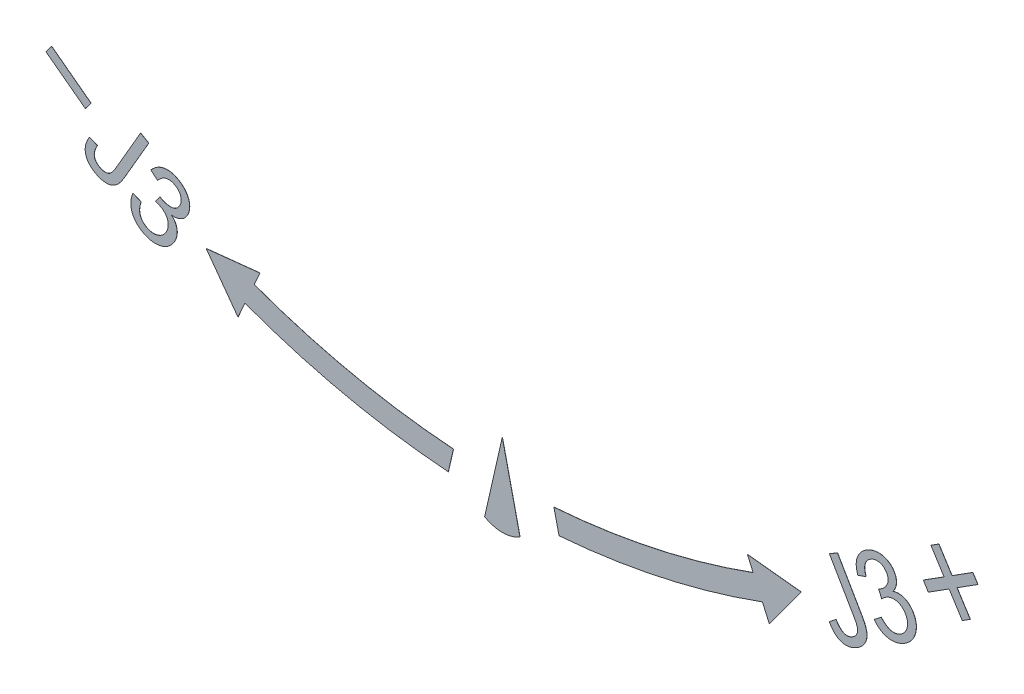
from build123d import *

# Parameters (mm, degrees)
ARROWS_DEPTH         = 0.25
ARROWS_2_DEPTH       = 0.25
ARROWS_3_DEPTH       = 0.25
ARROWS_4_DEPTH       = 0.25
ARROWS_5_DEPTH       = 0.25
EXTRUDE_J3_DEPTH     = 0.25
EXTRUDE_J3_2_DEPTH   = 0.25
EXTRUDE_J3_3_DEPTH   = 0.25
EXTRUDE_J3_3_2_DEPTH = 0.25
SCALE1_SCALE         = 0.040197


with BuildPart() as part:
    # Sketch2 → Arrows (new body)
    with BuildSketch(Plane.XY):
        Polygon((3334.452503995, 5315.005241882), (3404.956387353, 5262.127269884), (3415.176543069, 5275.523945484), (3344.562171664, 5328.484783611), align=None)
    extrude(amount=ARROWS_DEPTH)


with BuildPart() as body_2:
    # Sketch2 → Arrows 2 (new body)
    with BuildSketch(Plane.XY):
        with BuildLine():
            Line((3717.7345, 5163.4305418), (3621.4981418, 5153.2155))
            Line((3621.4981418, 5153.2155), (3678.4872582, 5075.2586582))
            Line((3678.4872582, 5075.2586582), (3690.8528418, 5103.2156))
            ThreePointArc((3690.8528418, 5103.2156), (3870.297184037, 5050.542510451), (4055.3682418, 5023.6458582))
            Line((4055.3682418, 5023.6458582), (4064.508, 5063.4307418))
            ThreePointArc((4064.508, 5063.4307418), (3883.312278545, 5089.327720839), (3707.5194582, 5140.3123))
            Line((3707.5194582, 5140.3123), (3717.7345, 5163.4305418))
        make_face()
    extrude(amount=ARROWS_2_DEPTH)


with BuildPart() as body_3:
    # Sketch2 → Arrows 3 (new body)
    with BuildSketch(Plane.XY):
        with BuildLine():
            Line((4152.1422418, 5125.7962), (4120.4218582, 4986.5491582))
            ThreePointArc((4120.4218582, 4986.5491582), (4152.1422291, 4977.889133987), (4183.8626, 4986.5491582))
            Line((4183.8626, 4986.5491582), (4152.1422418, 5125.7962))
        make_face()
    extrude(amount=ARROWS_3_DEPTH)


with BuildPart() as body_4:
    # Sketch2 → Arrows 4 (new body)
    with BuildSketch(Plane.XY):
        with BuildLine():
            Line((4244.6151582, 5063.4307418), (4253.7549418, 5023.6458582))
            ThreePointArc((4253.7549418, 5023.6458582), (4438.739441527, 5050.939039788), (4618.2703418, 5103.2156))
            Line((4618.2703418, 5103.2156), (4630.6359, 5075.2586582))
            Line((4630.6359, 5075.2586582), (4687.6250418, 5153.2155))
            Line((4687.6250418, 5153.2155), (4591.3886582, 5163.4305418))
            Line((4591.3886582, 5163.4305418), (4601.6037, 5140.3123))
            ThreePointArc((4601.6037, 5140.3123), (4425.773813147, 5089.49983388), (4244.6151582, 5063.4307418))
        make_face()
    extrude(amount=ARROWS_4_DEPTH)


with BuildPart() as body_5:
    # Sketch2 → Arrows 5 (new body)
    with BuildSketch(Plane.XY):
        Polygon((4943.789009697, 5304.797458242), (4906.53658973, 5281.186780004), (4915.556982848, 5266.954597881), (4952.809402815, 5290.565276119), (4976.420081053, 5253.312856151), (4990.652263176, 5262.33324927), (4967.041584938, 5299.585669237), (5004.294004906, 5323.196347475), (4995.273611787, 5337.428529598), (4958.02119182, 5313.81785136), (4934.410513582, 5351.070271327), (4920.178331459, 5342.049878209), align=None)
    extrude(amount=ARROWS_5_DEPTH)


with BuildPart() as body_6:
    # Sketch3 → Extrude J3 (new body)
    with BuildSketch(Plane.XY):
        with BuildLine():
            Line((3412.234669017, 5221.497851265), (3426.447409402, 5215.683548381))
            add(Edge.make_bspline(
                [(3426.447409402, 5215.683548381), (3425.907825179, 5214.648030824), (3424.868903002, 5212.654232434), (3423.600083312, 5209.676743101), (3422.513780011, 5206.904303824), (3421.701571316, 5204.307723437), (3421.188583028, 5201.883443078), (3420.869034172, 5199.645772534), (3420.876839735, 5197.579115798), (3421.097172013, 5195.673890927), (3421.587957166, 5193.92210397), (3422.220750805, 5192.255079287), (3423.092606822, 5190.694695951), (3424.134881311, 5189.224473751), (3425.321495291, 5187.806559807), (3426.741464141, 5186.515097147), (3428.332870346, 5185.303236172), (3429.498467296, 5184.594792296), (3430.09103921, 5184.234630111)],
                knots=[0, 0, 0, 0, 0.003501669, 0.006742158, 0.00970322, 0.012433367, 0.014891557, 0.017132018, 0.019199326, 0.021074382, 0.022867146, 0.024642693, 0.026412212, 0.028211668, 0.030044765, 0.031946519, 0.033957003, 0.036036067, 0.036036067, 0.036036067, 0.036036067], degree=3))
            add(Edge.make_bspline(
                [(3430.09103921, 5184.234630111), (3430.992556106, 5183.752706915), (3432.748125218, 5182.814233679), (3435.510512155, 5181.863242501), (3438.255851414, 5181.290401314), (3440.978146199, 5181.196890194), (3443.61607558, 5181.490834727), (3446.102895484, 5182.228631124), (3448.418849178, 5183.349409124), (3450.177205592, 5184.651000329), (3451.535445233, 5185.909398717), (3452.602136673, 5187.061763331), (3453.694503891, 5188.405812944), (3454.873481663, 5189.910813388), (3456.083141746, 5191.621958488), (3457.335770198, 5193.521282006), (3458.640526424, 5195.604359996), (3459.493972755, 5197.066707502), (3459.937794017, 5197.827178188)],
                knots=[0, 0, 0, 0, 0.003062499, 0.005963759, 0.008730835, 0.011446144, 0.01410014, 0.016659477, 0.019190478, 0.021780034, 0.023188091, 0.024742228, 0.026485897, 0.028382905, 0.030476692, 0.032770175, 0.035208043, 0.037849428, 0.037849428, 0.037849428, 0.037849428], degree=3))
            Line((3459.937794017, 5197.827178188), (3503.945606517, 5273.697370496))
            Line((3503.945606517, 5273.697370496), (3518.520125748, 5265.247250304))
            Line((3518.520125748, 5265.247250304), (3475.003298825, 5190.203981073))
            add(Edge.make_bspline(
                [(3475.003298825, 5190.203981073), (3474.348256837, 5189.08782766), (3473.075207943, 5186.91862646), (3471.08457427, 5183.84007894), (3469.091952121, 5181.028815442), (3467.137745433, 5178.444236224), (3465.142948049, 5176.165304305), (3463.199747011, 5174.090020997), (3461.252221663, 5172.288074338), (3459.284941646, 5170.74086057), (3457.306325301, 5169.411072566), (3455.279417136, 5168.263457621), (3453.197180393, 5167.307887487), (3451.047184742, 5166.556798333), (3448.855642451, 5165.960543931), (3446.592681221, 5165.533953414), (3444.273143095, 5165.350468663), (3441.108553457, 5165.260050335), (3437.08514313, 5165.697738066), (3432.236048826, 5166.808400578), (3427.364671143, 5168.63552157), (3424.249580199, 5170.31940219), (3422.648731517, 5171.184750304)],
                knots=[0, 0, 0, 0, 0.003882227, 0.007544959, 0.010993592, 0.014218795, 0.017259961, 0.020074889, 0.022744939, 0.025210859, 0.027576013, 0.02989022, 0.032191406, 0.034439009, 0.036714515, 0.039000416, 0.041335307, 0.043687437, 0.048490662, 0.053423923, 0.058583722, 0.064038634, 0.064038634, 0.064038634, 0.064038634], degree=3))
            add(Edge.make_bspline(
                [(3422.648731517, 5171.184750304), (3421.489124696, 5171.887454467), (3419.229652914, 5173.256660133), (3416.163633248, 5175.602138508), (3413.414031861, 5178.029363563), (3411.044246775, 5180.625747732), (3409.054280336, 5183.371511327), (3407.395251421, 5186.238718229), (3406.129604961, 5189.253385127), (3405.211262882, 5192.398653373), (3404.700740269, 5195.671963207), (3404.566125217, 5199.063763941), (3404.869600416, 5202.563976115), (3405.547811085, 5206.163763161), (3406.622379973, 5209.866641095), (3408.120832083, 5213.665383727), (3409.967279917, 5217.595999242), (3411.465080229, 5220.173499141), (3412.234669017, 5221.497851265)],
                knots=[0, 0, 0, 0, 0.004064984, 0.007920544, 0.011562341, 0.015056278, 0.018441889, 0.02171763, 0.024971691, 0.028226675, 0.031523447, 0.034885306, 0.038385449, 0.042039693, 0.045859058, 0.049933314, 0.054279579, 0.058872801, 0.058872801, 0.058872801, 0.058872801], degree=3))
        make_face()
    extrude(amount=EXTRUDE_J3_DEPTH)


with BuildPart() as body_7:
    # Sketch3 → Extrude J3 2 (new body)
    with BuildSketch(Plane.XY):
        with BuildLine():
            Line((3490.273570282, 5173.347957036), (3504.822248166, 5167.301082036))
            add(Edge.make_bspline(
                [(3504.822248166, 5167.301082036), (3504.482317338, 5166.26264159), (3503.821905369, 5164.245176733), (3503.067289604, 5161.241049969), (3502.56627198, 5158.379213499), (3502.200907297, 5155.665401962), (3502.09484397, 5153.08748777), (3502.225543455, 5150.64016088), (3502.553999094, 5148.336935763), (3503.097274235, 5146.170332174), (3503.857297971, 5144.140752142), (3504.793482222, 5142.225783274), (3505.876144888, 5140.41422255), (3507.119840783, 5138.716358982), (3508.567402222, 5137.159119479), (3510.158982769, 5135.690456569), (3511.920926843, 5134.335626535), (3513.19584077, 5133.558066775), (3513.840877974, 5133.164663767)],
                knots=[0, 0, 0, 0, 0.003277371, 0.006367223, 0.009281801, 0.011990216, 0.014576417, 0.017008938, 0.019333223, 0.02154564, 0.023696069, 0.025822609, 0.027932124, 0.030020163, 0.032123496, 0.034299853, 0.036511969, 0.038777328, 0.038777328, 0.038777328, 0.038777328], degree=3))
            add(Edge.make_bspline(
                [(3513.840877974, 5133.164663767), (3514.635372911, 5132.737971487), (3516.2024445, 5131.896358385), (3518.635136102, 5130.879457811), (3521.10677752, 5130.152559361), (3523.601576435, 5129.693910523), (3526.118631989, 5129.442169546), (3528.665890578, 5129.507818164), (3531.236229392, 5129.818178247), (3533.803207745, 5130.390942188), (3536.318474686, 5131.175756614), (3538.713113001, 5132.210058158), (3540.935106491, 5133.498321612), (3543.051765158, 5134.937002468), (3544.998303474, 5136.631998094), (3546.779941312, 5138.554023561), (3548.420851569, 5140.684867449), (3549.377212084, 5142.226158791), (3549.863714512, 5143.010216651)],
                knots=[0, 0, 0, 0, 0.002704467, 0.005334324, 0.007893661, 0.010417661, 0.012935038, 0.015468017, 0.018045035, 0.020690967, 0.023347101, 0.025939491, 0.028497262, 0.031041946, 0.033606627, 0.036221204, 0.038893379, 0.041660214, 0.041660214, 0.041660214, 0.041660214], degree=3))
            add(Edge.make_bspline(
                [(3549.863714512, 5143.010216651), (3550.282541871, 5143.77853387), (3551.108160455, 5145.293088645), (3552.082868241, 5147.63959978), (3552.821547596, 5150.000378958), (3553.313284327, 5152.362919777), (3553.551059795, 5154.744945861), (3553.525849748, 5157.128425514), (3553.23030935, 5159.515645438), (3552.719963591, 5161.888822988), (3551.965748717, 5164.204144331), (3551.026286173, 5166.435131041), (3549.8170905, 5168.511501726), (3548.418384771, 5170.462084289), (3546.796550731, 5172.277164337), (3544.993564327, 5173.986852045), (3542.958812929, 5175.555392431), (3541.474629312, 5176.454444945), (3540.715877974, 5176.914062805)],
                knots=[0, 0, 0, 0, 0.002623756, 0.005172111, 0.007607786, 0.01003536, 0.012398396, 0.01477594, 0.017170277, 0.019603209, 0.022046686, 0.024465993, 0.026850689, 0.029238882, 0.03165529, 0.034141437, 0.036684415, 0.039344191, 0.039344191, 0.039344191, 0.039344191], degree=3))
            add(Edge.make_bspline(
                [(3540.715877974, 5176.914062805), (3540.023676549, 5177.287234596), (3538.556464952, 5178.078221093), (3536.109853562, 5179.089891661), (3533.334758959, 5180.080542606), (3531.347858924, 5180.647058912), (3530.301815474, 5180.945312805)],
                knots=[0, 0, 0, 0, 0.002357802, 0.004997669, 0.007931886, 0.011194144, 0.011194144, 0.011194144, 0.011194144], degree=3))
            Line((3530.301815474, 5180.945312805), (3538.700252974, 5191.927884921))
            add(Edge.make_bspline(
                [(3538.700252974, 5191.927884921), (3539.074801893, 5191.645709633), (3539.743450205, 5191.141967612), (3540.454716228, 5190.700699144), (3540.767560666, 5190.506610882)],
                knots=[0, 0, 0, 0, 0.001405921, 0.002509864, 0.002509864, 0.002509864, 0.002509864], degree=3))
            add(Edge.make_bspline(
                [(3540.767560666, 5190.506610882), (3542.203847048, 5189.748285865), (3545.036879045, 5188.252512413), (3549.576027309, 5186.784789708), (3554.214997554, 5186.002678219), (3558.124204101, 5185.897634508), (3561.217261048, 5186.210454008), (3563.434621614, 5186.758986318), (3565.523893047, 5187.590374058), (3567.470796588, 5188.717861786), (3569.301487559, 5190.098580985), (3570.986342398, 5191.773145821), (3572.543403086, 5193.718349363), (3573.437397822, 5195.165052098), (3573.896166435, 5195.907452228)],
                knots=[0, 0, 0, 0, 0.004865453, 0.00959696, 0.014236112, 0.018940372, 0.021280406, 0.023542963, 0.025769521, 0.028003565, 0.030272459, 0.032629694, 0.035111674, 0.037727911, 0.037727911, 0.037727911, 0.037727911], degree=3))
            add(Edge.make_bspline(
                [(3573.896166435, 5195.907452228), (3574.23633915, 5196.521299384), (3574.906286609, 5197.730230388), (3575.674200429, 5199.622971553), (3576.25033733, 5201.516374261), (3576.621086725, 5203.421885784), (3576.763308631, 5205.336314292), (3576.757360236, 5207.26943013), (3576.475623301, 5209.20494101), (3576.049217253, 5211.148112753), (3575.403447264, 5213.03099049), (3574.599115029, 5214.84891038), (3573.586424342, 5216.552374434), (3572.390404912, 5218.154100342), (3571.031667328, 5219.676045213), (3569.488356451, 5221.083194296), (3567.757761477, 5222.397707384), (3566.504180073, 5223.163746146), (3565.859507782, 5223.557692613)],
                knots=[0, 0, 0, 0, 0.002103809, 0.004143312, 0.006113535, 0.008034331, 0.009952866, 0.0118653, 0.013820553, 0.015807818, 0.017826257, 0.019780997, 0.021762036, 0.023757015, 0.025769988, 0.027873321, 0.030013009, 0.032278368, 0.032278368, 0.032278368, 0.032278368], degree=3))
            add(Edge.make_bspline(
                [(3565.859507782, 5223.557692613), (3564.555001169, 5224.239453722), (3562.030657552, 5225.55872592), (3557.945227778, 5226.62647225), (3553.846152738, 5226.904444798), (3550.441256672, 5226.416263547), (3547.772392164, 5225.625238539), (3545.766751999, 5224.824383643), (3543.805441655, 5223.774246489), (3541.844573853, 5222.534512886), (3539.956065623, 5221.027483935), (3538.074604113, 5219.327847007), (3536.209197096, 5217.419362833), (3535.038332536, 5216.011959874), (3534.436430858, 5215.288461844)],
                knots=[0, 0, 0, 0, 0.004404036, 0.008522225, 0.012561749, 0.016658479, 0.018759906, 0.020904894, 0.023124243, 0.025425284, 0.02785492, 0.03036153, 0.033029579, 0.035852088, 0.035852088, 0.035852088, 0.035852088], degree=3))
            Line((3534.436430858, 5215.288461844), (3522.316839512, 5225.521634921))
            add(Edge.make_bspline(
                [(3522.316839512, 5225.521634921), (3523.180015788, 5226.501015927), (3524.865491528, 5228.413398105), (3527.609278889, 5230.984756159), (3530.428038401, 5233.260445918), (3533.314530681, 5235.267595734), (3536.305363688, 5236.928105698), (3539.378027951, 5238.280754917), (3542.53244894, 5239.346695227), (3545.769936404, 5240.095516168), (3549.049307417, 5240.534114618), (3552.345684761, 5240.665114806), (3555.642146828, 5240.482330727), (3558.929254952, 5239.988841604), (3562.218860112, 5239.182141048), (3565.485439142, 5238.03121032), (3568.774561732, 5236.609175707), (3570.898736196, 5235.445066073), (3571.98390682, 5234.850360882)],
                knots=[0, 0, 0, 0, 0.003914601, 0.007643822, 0.011263917, 0.014776154, 0.018177115, 0.021509346, 0.024835259, 0.028151218, 0.031462341, 0.034746734, 0.038033567, 0.041351942, 0.044705049, 0.048178284, 0.051730976, 0.055441527, 0.055441527, 0.055441527, 0.055441527], degree=3))
            add(Edge.make_bspline(
                [(3571.98390682, 5234.850360882), (3573.436945837, 5233.944523064), (3576.298040402, 5232.160890532), (3580.146492742, 5228.941415632), (3583.538605799, 5225.356315853), (3586.404124654, 5221.417117893), (3588.771043694, 5217.278159375), (3590.508008929, 5212.97940209), (3591.55233718, 5208.56110689), (3591.927275217, 5204.095805388), (3591.718535719, 5199.692842113), (3590.978511273, 5195.427791912), (3589.631743996, 5191.351186378), (3588.308403541, 5188.827969932), (3587.643762589, 5187.560697421)],
                knots=[0, 0, 0, 0, 0.005131769, 0.010104667, 0.015003903, 0.019903752, 0.024682794, 0.029275071, 0.033762918, 0.038250243, 0.042673947, 0.046952231, 0.051201542, 0.055489181, 0.055489181, 0.055489181, 0.055489181], degree=3))
            add(Edge.make_bspline(
                [(3587.643762589, 5187.560697421), (3586.919006217, 5186.416450249), (3585.494876844, 5184.168031234), (3582.793264008, 5181.233803902), (3579.722695105, 5178.734110044), (3576.278382835, 5176.687062962), (3572.491007389, 5175.149470346), (3568.408976777, 5174.165593505), (3564.037466386, 5173.779494983), (3561.061328327, 5173.955180974), (3559.528377974, 5174.045673382)],
                knots=[0, 0, 0, 0, 0.00405668, 0.007971281, 0.011902225, 0.015899707, 0.019945012, 0.02411925, 0.028452128, 0.0330545, 0.0330545, 0.0330545, 0.0330545], degree=3))
            add(Edge.make_bspline(
                [(3559.528377974, 5174.045673382), (3560.201862466, 5173.383569909), (3561.529174841, 5172.078687401), (3563.314740287, 5169.981943955), (3564.867097105, 5167.809769633), (3566.203139807, 5165.56419426), (3567.310644263, 5163.246437485), (3568.196531358, 5160.859789277), (3568.844580134, 5158.400815505), (3569.284005437, 5155.885491309), (3569.490401335, 5153.316365697), (3569.464423923, 5150.730351026), (3569.201913666, 5148.127780281), (3568.706264562, 5145.509044959), (3567.979524483, 5142.873736333), (3567.023729351, 5140.224353762), (3565.793044586, 5137.585964684), (3564.84430792, 5135.855583023), (3564.360709705, 5134.973557998)],
                knots=[0, 0, 0, 0, 0.002832311, 0.005581956, 0.008249504, 0.010833251, 0.013410788, 0.015945348, 0.018458876, 0.021029148, 0.023595781, 0.026180044, 0.028777068, 0.031432824, 0.034166149, 0.036970025, 0.039872205, 0.042889562, 0.042889562, 0.042889562, 0.042889562], degree=3))
            add(Edge.make_bspline(
                [(3564.360709705, 5134.973557998), (3563.640701113, 5133.813996189), (3562.221344975, 5131.528146837), (3559.761963001, 5128.385093176), (3557.021160357, 5125.608559672), (3554.059662955, 5123.131272565), (3550.841593727, 5120.975055099), (3547.356840371, 5119.159737864), (3543.621379737, 5117.689185482), (3539.682922369, 5116.56344369), (3535.636313374, 5115.786495968), (3531.541624116, 5115.420192555), (3527.462835995, 5115.469282812), (3523.387235366, 5115.947735012), (3519.320716661, 5116.816526063), (3515.279236542, 5118.170132657), (3511.22000728, 5119.861877616), (3508.608707744, 5121.29584639), (3507.277176051, 5122.027043575)],
                knots=[0, 0, 0, 0, 0.004092816, 0.008068186, 0.011942147, 0.015776867, 0.019632774, 0.02353952, 0.027541593, 0.031655565, 0.035811445, 0.039884634, 0.043967894, 0.048025891, 0.052177028, 0.056418237, 0.060795429, 0.065349668, 0.065349668, 0.065349668, 0.065349668], degree=3))
            add(Edge.make_bspline(
                [(3507.277176051, 5122.027043575), (3506.109180057, 5122.738863513), (3503.816502157, 5124.136106186), (3500.668432775, 5126.544630392), (3497.766271805, 5129.059060292), (3495.231828838, 5131.821935643), (3492.990496413, 5134.749191531), (3491.08541657, 5137.869553228), (3489.425260594, 5141.137617192), (3488.152478154, 5144.594700284), (3487.204958702, 5148.143298796), (3486.568022591, 5151.722192505), (3486.319031168, 5155.31511737), (3486.385163646, 5158.915906165), (3486.842485068, 5162.530158793), (3487.614133635, 5166.156654233), (3488.754299408, 5169.788784292), (3489.762176389, 5172.14992235), (3490.273570282, 5173.347957036)],
                knots=[0, 0, 0, 0, 0.00410064, 0.008049211, 0.011875563, 0.015606037, 0.019275599, 0.022918771, 0.0265591, 0.030255045, 0.033947103, 0.037566737, 0.041142193, 0.044734977, 0.048353688, 0.052053606, 0.055845862, 0.05975201, 0.05975201, 0.05975201, 0.05975201], degree=3))
        make_face()
    extrude(amount=EXTRUDE_J3_2_DEPTH)


with BuildPart() as body_8:
    # Sketch4 → Extrude J3 3 (new body)
    with BuildSketch(Plane.XY):
        with BuildLine():
            Line((4737.998555778, 5132.457239626), (4750.092305778, 5141.889330972))
            add(Edge.make_bspline(
                [(4750.092305778, 5141.889330972), (4750.729282759, 5140.909841493), (4751.954313628, 5139.026092339), (4753.860888128, 5136.414460486), (4755.749828141, 5134.125971487), (4757.618947637, 5132.153577996), (4759.436761002, 5130.459043856), (4761.246714568, 5129.105010458), (4763.033318574, 5128.06851429), (4764.801329474, 5127.342171163), (4766.564427786, 5126.860312145), (4768.338181716, 5126.642820486), (4770.12214357, 5126.5797564), (4771.925329008, 5126.742626316), (4773.736750694, 5127.104457275), (4775.560039593, 5127.686383371), (4777.404687656, 5128.461519156), (4778.600991675, 5129.120923885), (4779.215502893, 5129.459643472)],
                knots=[0, 0, 0, 0, 0.003504719, 0.006740258, 0.009694886, 0.012400217, 0.014887706, 0.017141095, 0.0191668, 0.021067149, 0.022859913, 0.024632449, 0.02641625, 0.028206032, 0.030050749, 0.031946877, 0.033938673, 0.036042483, 0.036042483, 0.036042483, 0.036042483], degree=3))
            add(Edge.make_bspline(
                [(4779.215502893, 5129.459643472), (4780.086782786, 5129.993857825), (4781.78163353, 5131.03303433), (4783.956218836, 5132.982122656), (4785.800139238, 5135.088010275), (4787.253069861, 5137.388511927), (4788.290347953, 5139.833755204), (4788.93129776, 5142.344171889), (4789.082063594, 5144.918919354), (4788.775685211, 5147.607950632), (4787.935448832, 5150.572466103), (4786.549272478, 5153.965045674), (4784.618517197, 5157.888962234), (4783.071963768, 5160.640849889), (4782.238940393, 5162.123105011)],
                knots=[0, 0, 0, 0, 0.003060427, 0.005953273, 0.008719746, 0.011437022, 0.01407689, 0.016659086, 0.019170487, 0.021770209, 0.024741514, 0.028383677, 0.032752317, 0.037852564, 0.037852564, 0.037852564, 0.037852564], degree=3))
            Line((4782.238940393, 5162.123105011), (4738.231127893, 5237.993297319))
            Line((4738.231127893, 5237.993297319), (4752.805647124, 5246.443417511))
            Line((4752.805647124, 5246.443417511), (4796.322474047, 5171.40014828))
            add(Edge.make_bspline(
                [(4796.322474047, 5171.40014828), (4796.958950664, 5170.275941893), (4798.197150204, 5168.088914445), (4799.876000005, 5164.829688533), (4801.35016138, 5161.713636075), (4802.614394824, 5158.729221564), (4803.600899112, 5155.860540117), (4804.453846398, 5153.147752667), (4805.056909172, 5150.556792339), (4805.411712358, 5148.083111743), (4805.61169647, 5145.700381295), (4805.577713551, 5143.374592312), (4805.369898222, 5141.08549883), (4804.991533856, 5138.833680093), (4804.387476092, 5136.632474787), (4803.605237624, 5134.474296899), (4802.650933726, 5132.355083657), (4801.121372739, 5129.58408753), (4798.790252655, 5126.280596514), (4795.372100166, 5122.662887018), (4791.38515867, 5119.324061737), (4788.363474265, 5117.466407722), (4786.812858663, 5116.513129049)],
                knots=[0, 0, 0, 0, 0.00387534, 0.007539075, 0.010995445, 0.014215675, 0.017255962, 0.020092513, 0.022744117, 0.02522556, 0.027584069, 0.029909934, 0.03219335, 0.034474718, 0.036750224, 0.03903086, 0.041355576, 0.043714935, 0.048518437, 0.053436515, 0.05861124, 0.064065785, 0.064065785, 0.064065785, 0.064065785], degree=3))
            add(Edge.make_bspline(
                [(4786.812858663, 5116.513129049), (4785.626549797, 5115.853506819), (4783.31650773, 5114.569056247), (4779.758645237, 5113.061479475), (4776.289300094, 5111.857083671), (4772.851803984, 5111.120754957), (4769.485076896, 5110.702061952), (4766.171315443, 5110.746266075), (4762.925654013, 5111.121029669), (4759.750536002, 5111.907874801), (4756.648657129, 5113.077423228), (4753.650665449, 5114.6637987), (4750.754123831, 5116.648510311), (4747.991392292, 5119.057128186), (4745.294489765, 5121.818100333), (4742.746575822, 5125.009384871), (4740.239061449, 5128.542696261), (4738.760703403, 5131.125638477), (4737.998555778, 5132.457239626)],
                knots=[0, 0, 0, 0, 0.004069253, 0.00792386, 0.011576642, 0.01506905, 0.018450714, 0.021732667, 0.024986009, 0.028232571, 0.031520216, 0.03490701, 0.038383319, 0.04202988, 0.045885787, 0.04994584, 0.054268766, 0.058868961, 0.058868961, 0.058868961, 0.058868961], degree=3))
        make_face()
    extrude(amount=EXTRUDE_J3_3_DEPTH)


with BuildPart() as body_9:
    # Sketch4 → Extrude J3 3 2 (new body)
    with BuildSketch(Plane.XY):
        with BuildLine():
            Line((4818.608068327, 5176.199898071), (4831.089438519, 5185.812878841))
            add(Edge.make_bspline(
                [(4831.089438519, 5185.812878841), (4831.820815394, 5185.002845259), (4833.24229141, 5183.428495089), (4835.470567999, 5181.280696029), (4837.689773635, 5179.39125525), (4839.889845723, 5177.758121292), (4842.059694947, 5176.361968189), (4844.246983086, 5175.286670358), (4846.398226517, 5174.408582347), (4848.551836235, 5173.818623401), (4850.690540618, 5173.45396351), (4852.810917322, 5173.296946707), (4854.922591363, 5173.349795633), (4857.018185415, 5173.605768726), (4859.089685436, 5174.083062457), (4861.156077898, 5174.724810687), (4863.190113645, 5175.609851593), (4864.507490772, 5176.327635621), (4865.174174096, 5176.690883648)],
                knots=[0, 0, 0, 0, 0.003273294, 0.006361848, 0.009276885, 0.012010943, 0.014577576, 0.017004462, 0.019312602, 0.021538261, 0.023687913, 0.025812568, 0.027906355, 0.030015395, 0.032134386, 0.034275634, 0.03649814, 0.03877526, 0.03877526, 0.03877526, 0.03877526], degree=3))
            add(Edge.make_bspline(
                [(4865.174174096, 5176.690883648), (4865.943589528, 5177.15669368), (4867.464134568, 5178.077243364), (4869.517422629, 5179.727333169), (4871.403311192, 5181.474993899), (4873.033958451, 5183.417900881), (4874.494183038, 5185.478814822), (4875.716560539, 5187.716492188), (4876.6856458, 5190.118308913), (4877.500215545, 5192.624995413), (4878.014940738, 5195.211064064), (4878.354988499, 5197.793006005), (4878.36777989, 5200.367305885), (4878.137783572, 5202.920351006), (4877.651782849, 5205.454816218), (4876.845059169, 5207.940624406), (4875.861387432, 5210.443119005), (4874.978168874, 5212.033605029), (4874.528741404, 5212.842926917)],
                knots=[0, 0, 0, 0, 0.002695439, 0.005326819, 0.007886026, 0.010397427, 0.012920898, 0.015453482, 0.018025702, 0.020681835, 0.02334763, 0.025924649, 0.028483073, 0.031051916, 0.03360616, 0.036205239, 0.038882907, 0.041657093, 0.041657093, 0.041657093, 0.041657093], degree=3))
            add(Edge.make_bspline(
                [(4874.528741404, 5212.842926917), (4874.067872952, 5213.592245925), (4873.162731754, 5215.063901233), (4871.60995076, 5217.085932704), (4869.916348521, 5218.87016937), (4868.122929741, 5220.484279574), (4866.15447973, 5221.835401356), (4864.074531884, 5223.012250124), (4861.870201275, 5223.978431062), (4859.541370317, 5224.685004662), (4857.166984413, 5225.208473919), (4854.766910446, 5225.472417285), (4852.37707314, 5225.463651368), (4849.986354438, 5225.236441235), (4847.602683877, 5224.744582867), (4845.2407464, 5223.974713313), (4842.869468906, 5223.002015029), (4841.349363958, 5222.16150604), (4840.573212557, 5221.732349994)],
                knots=[0, 0, 0, 0, 0.00263797, 0.005180947, 0.007630565, 0.010010496, 0.012404833, 0.014776753, 0.017172345, 0.01960802, 0.02206621, 0.024457617, 0.026835021, 0.029223773, 0.031651347, 0.034119433, 0.036667788, 0.039326434, 0.039326434, 0.039326434, 0.039326434], degree=3))
            add(Edge.make_bspline(
                [(4840.573212557, 5221.732349994), (4839.911751211, 5221.32026363), (4838.498314049, 5220.439700942), (4836.403110996, 5218.824937319), (4834.16627975, 5216.90387601), (4832.691881641, 5215.461945973), (4831.916361596, 5214.703503841)],
                knots=[0, 0, 0, 0, 0.002336749, 0.00499326, 0.007925086, 0.011178428, 0.011178428, 0.011178428, 0.011178428], degree=3))
            Line((4831.916361596, 5214.703503841), (4826.51552025, 5227.443287494))
            add(Edge.make_bspline(
                [(4826.51552025, 5227.443287494), (4826.949347942, 5227.635034584), (4827.721667387, 5227.976391321), (4828.464145709, 5228.37831186), (4828.789558711, 5228.554465379)],
                knots=[0, 0, 0, 0, 0.001422213, 0.002531888, 0.002531888, 0.002531888, 0.002531888], degree=3))
            add(Edge.make_bspline(
                [(4828.789558711, 5228.554465379), (4830.172139156, 5229.417705285), (4832.886668421, 5231.112572298), (4836.402332348, 5234.340340069), (4839.413219505, 5237.94839767), (4841.416812792, 5241.312260222), (4842.681761847, 5244.143945174), (4843.310712106, 5246.335920847), (4843.61357574, 5248.553185611), (4843.659148706, 5250.797873757), (4843.317464528, 5253.069295114), (4842.731194974, 5255.371481113), (4841.814842829, 5257.696142582), (4840.995262238, 5259.185001148), (4840.573212557, 5259.951700956)],
                knots=[0, 0, 0, 0, 0.0048808, 0.00958286, 0.014244771, 0.018938018, 0.02127591, 0.023533444, 0.025751739, 0.027974245, 0.030243728, 0.032619165, 0.035090494, 0.03771425, 0.03771425, 0.03771425, 0.03771425], degree=3))
            add(Edge.make_bspline(
                [(4840.573212557, 5259.951700956), (4840.204901874, 5260.553060358), (4839.483699774, 5261.73060335), (4838.237061243, 5263.350379709), (4836.85315501, 5264.761516199), (4835.408064753, 5266.056081427), (4833.810498293, 5267.141747125), (4832.114025359, 5268.067578128), (4830.307822347, 5268.831995708), (4828.406574553, 5269.388359633), (4826.451322565, 5269.770033099), (4824.471226073, 5269.996318027), (4822.485841032, 5269.959242555), (4820.494686051, 5269.724986313), (4818.516231836, 5269.279459682), (4816.521314372, 5268.656609681), (4814.533204846, 5267.801310835), (4813.24445432, 5267.086681566), (4812.587034673, 5266.722133648)],
                knots=[0, 0, 0, 0, 0.002114732, 0.004140931, 0.006114709, 0.00803759, 0.00995142, 0.011894167, 0.013828302, 0.01582328, 0.017825109, 0.019799902, 0.021789853, 0.023767519, 0.02580522, 0.02786476, 0.03002958, 0.032283858, 0.032283858, 0.032283858, 0.032283858], degree=3))
            add(Edge.make_bspline(
                [(4812.587034673, 5266.722133648), (4811.950464393, 5266.337536137), (4810.692685992, 5265.57762249), (4808.978435819, 5264.260980992), (4807.422997331, 5262.849795888), (4806.056770152, 5261.318172049), (4804.833937389, 5259.69156283), (4803.787924513, 5257.944917464), (4802.944385793, 5256.085529105), (4802.26542618, 5254.131607108), (4801.771574109, 5252.090121991), (4801.491568699, 5249.95153746), (4801.404033786, 5247.726048352), (4801.594890076, 5245.414058275), (4801.877284602, 5243.006006808), (4802.44313528, 5240.523137901), (4803.191184389, 5237.950105186), (4803.832579403, 5236.234101422), (4804.162755827, 5235.350739417)],
                knots=[0, 0, 0, 0, 0.002229705, 0.004405602, 0.006472425, 0.00852189, 0.010553026, 0.012569479, 0.014616173, 0.016667429, 0.018767108, 0.020905079, 0.023128786, 0.025433887, 0.027857055, 0.030396485, 0.033062281, 0.035890462, 0.035890462, 0.035890462, 0.035890462], degree=3))
            Line((4804.162755827, 5235.350739417), (4789.252299096, 5229.924056725))
            add(Edge.make_bspline(
                [(4789.252299096, 5229.924056725), (4788.840175354, 5231.159483272), (4788.031984764, 5233.582202493), (4787.112557032, 5237.231133476), (4786.557093223, 5240.813234679), (4786.244218761, 5244.31171305), (4786.314277432, 5247.736981367), (4786.637164477, 5251.085741314), (4787.288588997, 5254.356972317), (4788.243904884, 5257.531609385), (4789.491845717, 5260.592856576), (4791.005005534, 5263.521190091), (4792.84764491, 5266.260175902), (4794.875112605, 5268.89355387), (4797.225711231, 5271.331614196), (4799.854825501, 5273.597644803), (4802.71058639, 5275.763286519), (4804.787942857, 5277.016746216), (4805.842443327, 5277.653023071)],
                knots=[0, 0, 0, 0, 0.003906405, 0.007660611, 0.011271748, 0.014771892, 0.018183341, 0.021533759, 0.02485324, 0.02817242, 0.031464328, 0.034758466, 0.038041029, 0.041354571, 0.044717522, 0.048179201, 0.051760816, 0.055453236, 0.055453236, 0.055453236, 0.055453236], degree=3))
            add(Edge.make_bspline(
                [(4805.842443327, 5277.653023071), (4807.340061046, 5278.467951457), (4810.299886435, 5280.078539857), (4815.015086476, 5281.779480951), (4819.799746382, 5282.986821698), (4824.640791099, 5283.497070935), (4829.405981047, 5283.505067875), (4834.000613324, 5282.856412168), (4838.359320097, 5281.59009827), (4842.412838253, 5279.684913257), (4846.126061739, 5277.305156406), (4849.472123629, 5274.544927412), (4852.323417834, 5271.325760734), (4853.859822976, 5268.931542285), (4854.630904865, 5267.729946148)],
                knots=[0, 0, 0, 0, 0.005108227, 0.010095674, 0.014990614, 0.019879002, 0.024659721, 0.029253451, 0.033750885, 0.038225096, 0.042640867, 0.046952037, 0.05119899, 0.055477899, 0.055477899, 0.055477899, 0.055477899], degree=3))
            add(Edge.make_bspline(
                [(4854.630904865, 5267.729946148), (4855.262094665, 5266.540595289), (4856.509701183, 5264.189730486), (4857.727237927, 5260.391313583), (4858.338295148, 5256.478521796), (4858.42292261, 5252.477227195), (4857.914177499, 5248.427689429), (4856.714725233, 5244.40149496), (4854.898605261, 5240.413979454), (4853.253798583, 5237.92293119), (4852.408549096, 5236.642806725)],
                knots=[0, 0, 0, 0, 0.00403332, 0.00797224, 0.011897744, 0.015878066, 0.019942311, 0.024088297, 0.028436175, 0.033032522, 0.033032522, 0.033032522, 0.033032522], degree=3))
            add(Edge.make_bspline(
                [(4852.408549096, 5236.642806725), (4853.318549236, 5236.895778768), (4855.107588543, 5237.393115974), (4857.808098882, 5237.926955185), (4860.46554912, 5238.168505585), (4863.074943234, 5238.234532105), (4865.627822364, 5238.054557479), (4868.135587758, 5237.634495536), (4870.594242559, 5236.990604113), (4872.992735472, 5236.103390561), (4875.332554696, 5235.030004082), (4877.548185354, 5233.684737558), (4879.713341642, 5232.205152004), (4881.725796085, 5230.449779045), (4883.645470878, 5228.507665017), (4885.453897578, 5226.352041466), (4887.169455771, 5223.997708176), (4888.193695986, 5222.308766224), (4888.715640442, 5221.448095187)],
                knots=[0, 0, 0, 0, 0.002833136, 0.005569879, 0.008244053, 0.010828704, 0.013393385, 0.015908373, 0.018446883, 0.021005698, 0.0235722, 0.026155947, 0.028772567, 0.031429706, 0.034152383, 0.036958163, 0.039863103, 0.042881677, 0.042881677, 0.042881677, 0.042881677], degree=3))
            add(Edge.make_bspline(
                [(4888.715640442, 5221.448095187), (4889.368823341, 5220.245525247), (4890.651478964, 5217.884037987), (4892.135742805, 5214.175812123), (4893.186525289, 5210.421738576), (4893.888829723, 5206.61666746), (4894.10055891, 5202.748550423), (4893.942813854, 5198.829506085), (4893.407743223, 5194.850714602), (4892.409017579, 5190.879263989), (4891.089139731, 5186.967899586), (4889.379829948, 5183.232367285), (4887.296236339, 5179.718895818), (4884.851325877, 5176.430815098), (4882.073039496, 5173.333769639), (4878.923464469, 5170.464172809), (4875.434450748, 5167.778371266), (4872.882358548, 5166.235520738), (4871.582827942, 5165.449898071)],
                knots=[0, 0, 0, 0, 0.004103, 0.008057064, 0.01195097, 0.015783164, 0.019640542, 0.023545665, 0.027536459, 0.031660482, 0.03581186, 0.039905247, 0.043960363, 0.048043377, 0.0521788, 0.056421977, 0.060809987, 0.06536254, 0.06536254, 0.06536254, 0.06536254], degree=3))
            add(Edge.make_bspline(
                [(4871.582827942, 5165.449898071), (4870.386671594, 5164.793252953), (4868.030047106, 5163.499554209), (4864.39272565, 5161.924399965), (4860.7392832, 5160.72772533), (4857.092754452, 5159.86397851), (4853.431608654, 5159.369767477), (4849.770223626, 5159.239065295), (4846.108573718, 5159.473319502), (4842.475985313, 5160.071565146), (4838.927264857, 5160.992332927), (4835.518739971, 5162.241445965), (4832.272389428, 5163.797582284), (4829.197061871, 5165.665239092), (4826.268439005, 5167.822341989), (4823.544913323, 5170.324214222), (4820.921548141, 5173.084586532), (4819.38841894, 5175.149084809), (4818.608068327, 5176.199898071)],
                knots=[0, 0, 0, 0, 0.004092081, 0.008062073, 0.011870144, 0.015612235, 0.019288796, 0.022934716, 0.026585761, 0.030277548, 0.033962999, 0.037568306, 0.041151319, 0.044745496, 0.048347839, 0.052043423, 0.055828011, 0.059751218, 0.059751218, 0.059751218, 0.059751218], degree=3))
        make_face()
    extrude(amount=EXTRUDE_J3_3_2_DEPTH)


with BuildPart() as body_9_1:
    # Scale1: scaled about (0, 0, 0)
    add(body_9.part.scale(SCALE1_SCALE))


with BuildPart() as body_8_1:
    # Scale1: scaled about (0, 0, 0)
    add(body_8.part.scale(SCALE1_SCALE))


with BuildPart() as body_7_1:
    # Scale1: scaled about (0, 0, 0)
    add(body_7.part.scale(SCALE1_SCALE))


with BuildPart() as body_6_1:
    # Scale1: scaled about (0, 0, 0)
    add(body_6.part.scale(SCALE1_SCALE))


with BuildPart() as body_5_1:
    # Scale1: scaled about (0, 0, 0)
    add(body_5.part.scale(SCALE1_SCALE))


with BuildPart() as body_4_1:
    # Scale1: scaled about (0, 0, 0)
    add(body_4.part.scale(SCALE1_SCALE))


with BuildPart() as body_3_1:
    # Scale1: scaled about (0, 0, 0)
    add(body_3.part.scale(SCALE1_SCALE))


with BuildPart() as body_2_1:
    # Scale1: scaled about (0, 0, 0)
    add(body_2.part.scale(SCALE1_SCALE))


with BuildPart() as part_1:
    # Scale1: scaled about (0, 0, 0)
    add(part.part.scale(SCALE1_SCALE))


solid = Compound([body_9_1.part, body_8_1.part, body_7_1.part, body_6_1.part, body_5_1.part, body_4_1.part, body_3_1.part, body_2_1.part, part_1.part])
